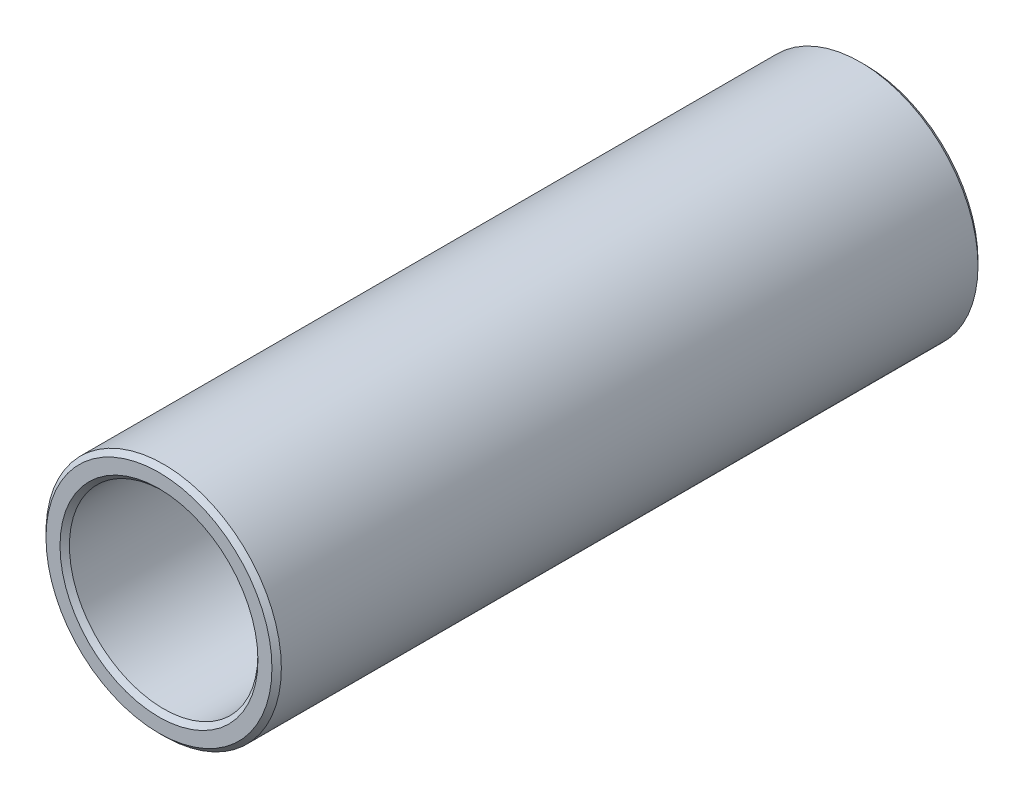
from build123d import *

# Parameters (mm, degrees)
ESQUISSE1_R        = 5
ESQUISSE1_R_2      = 4.005
BOSS_EXTRU_1_DEPTH = 30
CHANFREIN1_SIZE    = 0.2


with BuildPart() as part:
    # Esquisse1 → Boss.-Extru.1 (new body)
    with BuildSketch(Plane.XY):
        Circle(ESQUISSE1_R)
        Circle(ESQUISSE1_R_2, mode=Mode.SUBTRACT)
    extrude(amount=BOSS_EXTRU_1_DEPTH)

    # Chanfrein1
    chanfrein1_edges = [part.edges().sort_by_distance(p)[0] for p in [
        (-5, 0, 0),
        (-5, 0, 30),
        (-4.005, 0, 0),
        (-4.005, 0, 30),
    ]]
    chamfer(chanfrein1_edges, length=CHANFREIN1_SIZE)


solid = part.part
